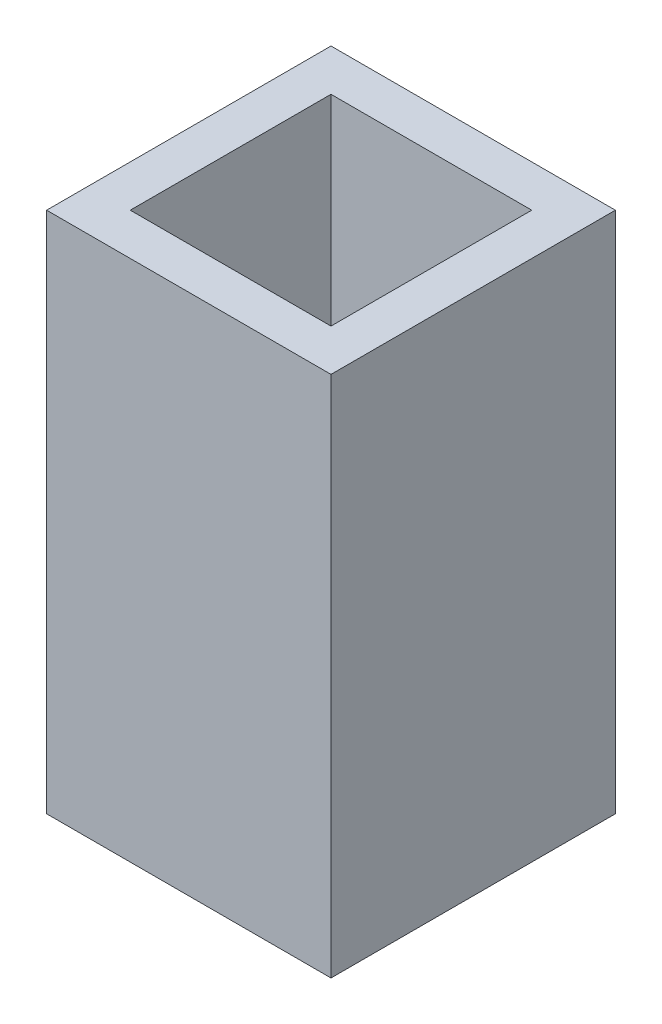
from build123d import *

# Parameters (mm, degrees)
SKETCH1_W           = 13.6
SKETCH1_H           = 13.6
SKETCH1_W_2         = 9.6
SKETCH1_H_2         = 9.6
BOSS_EXTRUDE1_DEPTH = 25


with BuildPart() as part:
    # Sketch1 → Boss-Extrude1 (new body)
    with BuildSketch(Plane(origin=(0, 0, 0), x_dir=(1, 0, 0), z_dir=(0, 1, 0))):
        Rectangle(SKETCH1_W, SKETCH1_H)
        Rectangle(SKETCH1_W_2, SKETCH1_H_2, mode=Mode.SUBTRACT)
    extrude(amount=BOSS_EXTRUDE1_DEPTH)


solid = part.part
